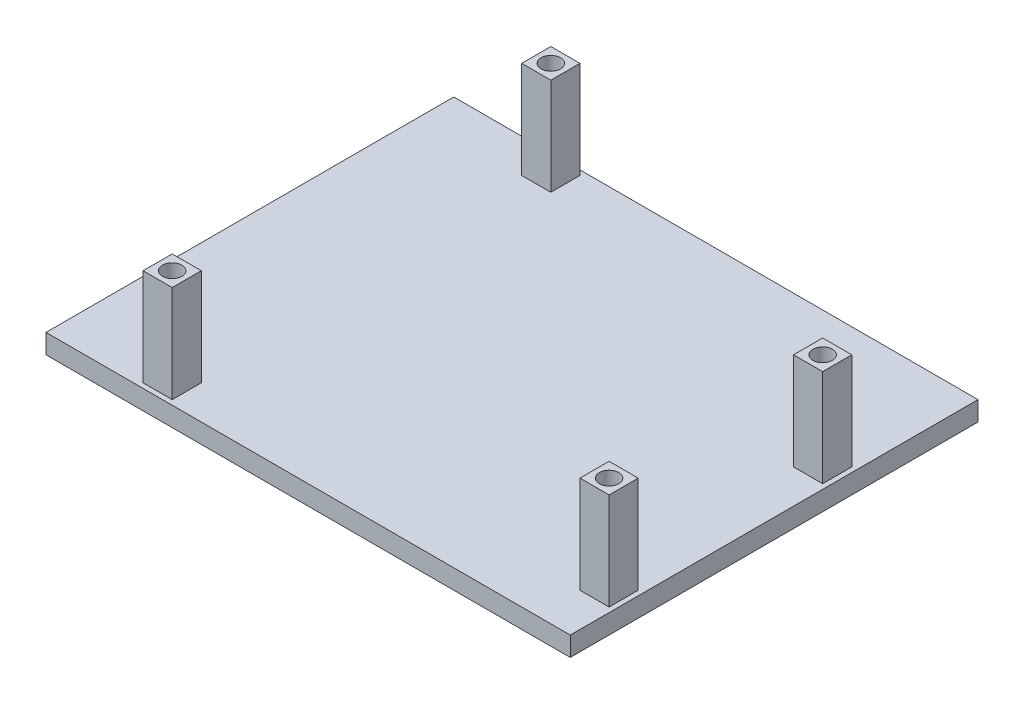
from build123d import *

# Parameters (mm, degrees)
SKETCH1_W           = 68.58
SKETCH1_H           = 53.34
BOSS_EXTRUDE1_DEPTH = 2.54
SKETCH2_W           = 3.81
SKETCH2_H           = 3.81
SKETCH2_R           = 1.27
BOSS_EXTRUDE2_DEPTH = 12.7
SKETCH3_W           = 3.81
SKETCH3_H           = 3.81
SKETCH3_R           = 1.27
BOSS_EXTRUDE3_DEPTH = 12.7


with BuildPart() as part:
    # Sketch1 → Boss-Extrude1 (new body)
    with BuildSketch(Plane(origin=(0, 0, 0), x_dir=(1, 0, 0), z_dir=(0, 1, 0))):
        with Locations((34.29, 26.67)):
            Rectangle(SKETCH1_W, SKETCH1_H)
    extrude(amount=BOSS_EXTRUDE1_DEPTH)

    # Sketch2 → Boss-Extrude2 (add)
    with BuildSketch(Plane(origin=(0, 2.54, 0), x_dir=(1, 0, 0), z_dir=(0, 1, 0))):
        with Locations((13.97, 2.54)):
            Rectangle(SKETCH2_W, SKETCH2_H)
        with Locations((13.97, 2.54)):
            Circle(SKETCH2_R, mode=Mode.SUBTRACT)
    extrude(amount=BOSS_EXTRUDE2_DEPTH)

    # Sketch3 → Boss-Extrude3 (add)
    with BuildSketch(Plane(origin=(0, 2.54, 0), x_dir=(1, 0, 0), z_dir=(0, 1, 0))):
        with Locations((15.24, 50.8)):
            Rectangle(SKETCH3_W, SKETCH3_H)
        with Locations((15.24, 50.8)):
            Circle(SKETCH3_R, mode=Mode.SUBTRACT)
        with Locations((66.04, 35.56)):
            Rectangle(SKETCH3_W, SKETCH3_H)
        with Locations((66.04, 35.56)):
            Circle(SKETCH3_R, mode=Mode.SUBTRACT)
        with Locations((66.04, 7.62)):
            Rectangle(SKETCH3_W, SKETCH3_H)
        with Locations((66.04, 7.62)):
            Circle(SKETCH3_R, mode=Mode.SUBTRACT)
    extrude(amount=BOSS_EXTRUDE3_DEPTH)


solid = part.part
